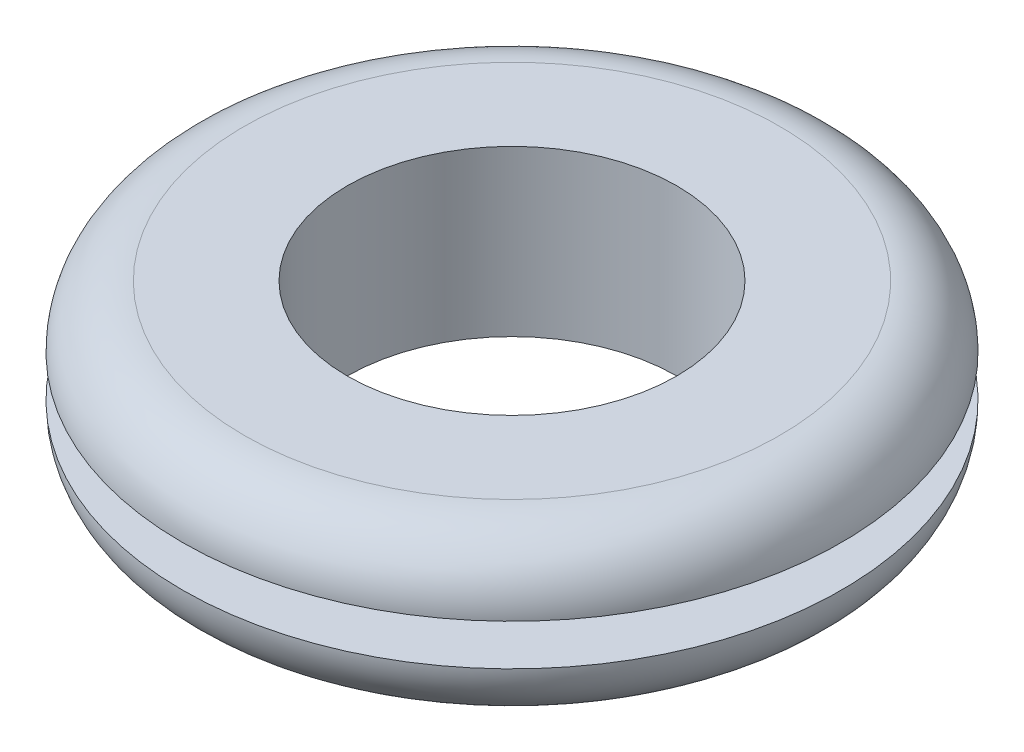
from build123d import *


with BuildPart() as part:
    # Sketch2 → Revolve1 (revolve)
    with BuildSketch(Plane.XY):
        with BuildLine():
            Line((9.525, 0.79375), (12.7, 0.79375))
            ThreePointArc((12.7, 0.79375), (12.002548023, 2.477548023), (10.31875, 3.175))
            Line((10.31875, 3.175), (6.35, 3.175))
            Line((6.35, 3.175), (6.35, -3.175))
            Line((6.35, -3.175), (10.31875, -3.175))
            ThreePointArc((10.31875, -3.175), (12.002548023, -2.477548023), (12.7, -0.79375))
            Line((12.7, -0.79375), (9.525, -0.79375))
            Line((9.525, -0.79375), (9.525, 0.79375))
        make_face()
    revolve(axis=Axis((0, 3.175, 0), (0, -1, 0)))


solid = part.part
